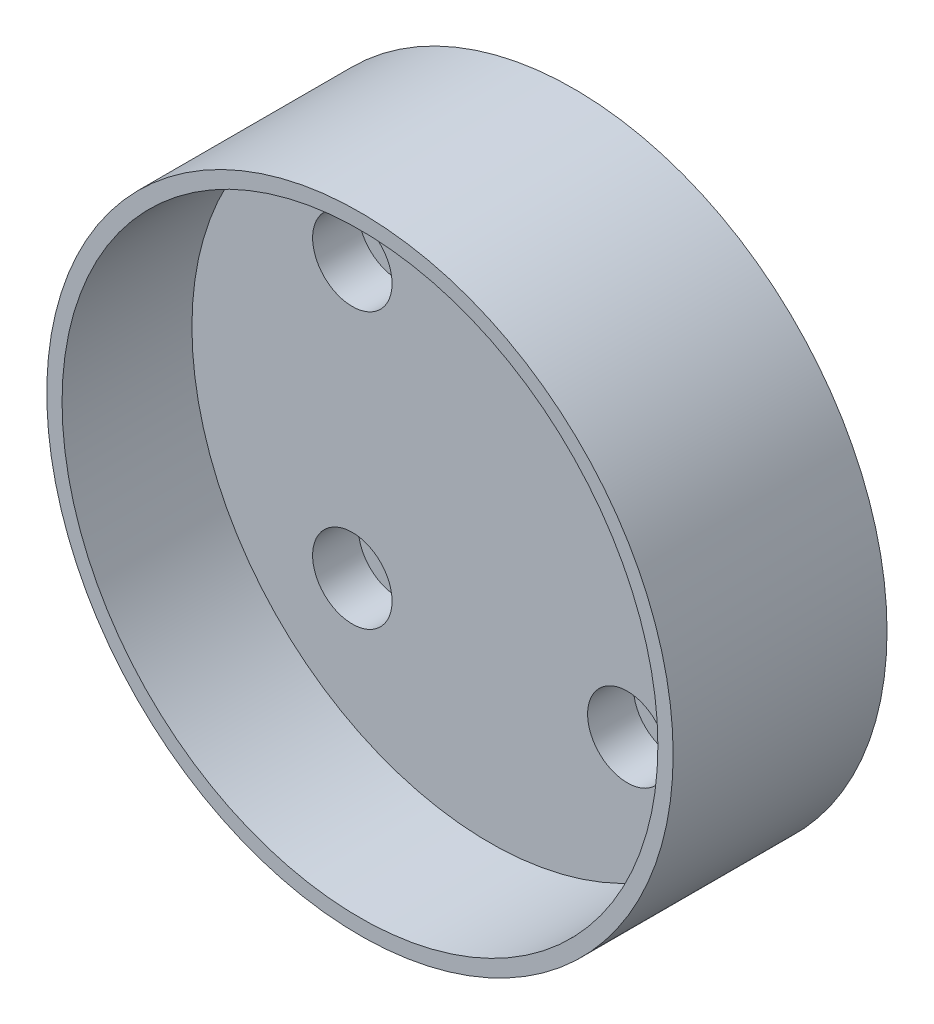
from build123d import *

# Parameters (mm, degrees)
SCHIZZO2_R                   = 41
ESTRUSIONE_ESTRUSIONE1_DEPTH = 28
SCHIZZO3_R                   = 39
TAGLIO_ESTRUSIONE1_DEPTH     = 17
SCHIZZO4_R                   = 2.75
TAGLIO_ESTRUSIONE3_DEPTH     = 29
SCHIZZO5_R                   = 5.2
TAGLIO_ESTRUSIONE4_DEPTH     = 6


with BuildPart() as part:
    # Schizzo2 → Estrusione-Estrusione1 (new body)
    with BuildSketch(Plane.XY):
        Circle(SCHIZZO2_R)
    extrude(amount=ESTRUSIONE_ESTRUSIONE1_DEPTH)

    # Schizzo3 → Taglio-Estrusione1 (cut)
    with BuildSketch(Plane.XY.offset(28)):
        Circle(SCHIZZO3_R)
    extrude(amount=-TAGLIO_ESTRUSIONE1_DEPTH, mode=Mode.SUBTRACT)

    # Schizzo4 → Taglio-Estrusione3 (cut, through all)
    with BuildSketch(Plane(origin=(0, 0, 0), x_dir=(-1, 0, 0), z_dir=(0, 0, -1))):
        with Locations((-18, 18)):
            Circle(SCHIZZO4_R)
        with Locations((18, 18)):
            Circle(SCHIZZO4_R)
        with Locations((18, -18)):
            Circle(SCHIZZO4_R)
        with Locations((-18, -18)):
            Circle(SCHIZZO4_R)
    extrude(amount=-TAGLIO_ESTRUSIONE3_DEPTH, mode=Mode.SUBTRACT)

    # Schizzo5 → Taglio-Estrusione4 (cut)
    with BuildSketch(Plane.XY.offset(11)):
        with Locations((-18, 18)):
            Circle(SCHIZZO5_R)
        with Locations((18, 18)):
            Circle(SCHIZZO5_R)
        with Locations((18, -18)):
            Circle(SCHIZZO5_R)
        with Locations((-18, -18)):
            Circle(SCHIZZO5_R)
    extrude(amount=-TAGLIO_ESTRUSIONE4_DEPTH, mode=Mode.SUBTRACT)


solid = part.part
